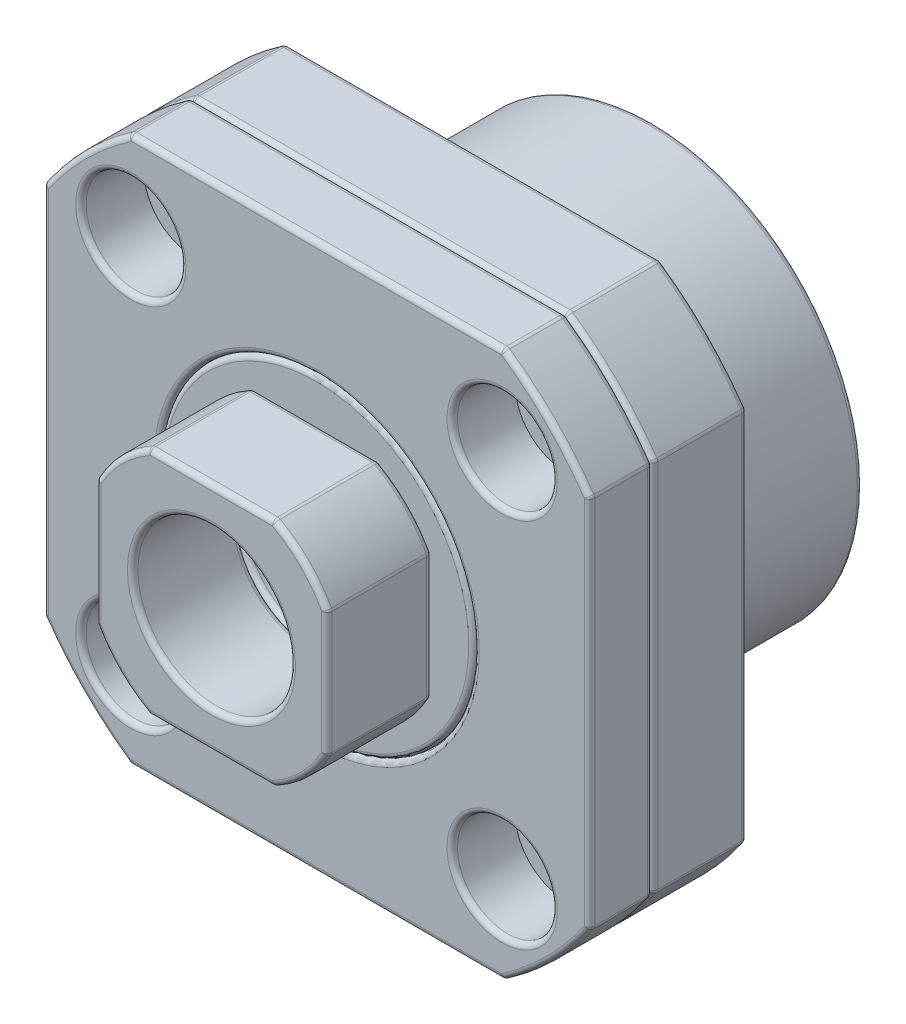
from build123d import *

# Parameters (mm, degrees)
SKETCH1_W            = 52
SKETCH1_H            = 52
SKETCH1_R            = 4.75
BOSS_EXTRUDE1_DEPTH  = 6
SKETCH2_OUTSIDE_W    = 68.756
SKETCH2_OUTSIDE_H    = 68.756
SKETCH2_OUTSIDE_R    = 31.5
CUT_EXTRUDE2_DEPTH   = 6
SKETCH3_R            = 16
BOSS_EXTRUDE2_DEPTH  = 1
SKETCH4_R            = 15
CUT_EXTRUDE3_DEPTH   = 7
SKETCH5_R            = 15
SKETCH5_R_2          = 7.5
BOSS_EXTRUDE4_DEPTH  = 7
FILLET1_R            = 0.5
SKETCH6_W            = 52
SKETCH6_H            = 52
SKETCH6_R            = 16
SKETCH6_R_2          = 2.75
BOSS_EXTRUDE5_DEPTH  = 9
SKETCH7_OUTSIDE_W    = 69.01
SKETCH7_OUTSIDE_H    = 69.01
SKETCH7_OUTSIDE_R    = 31.5
CUT_EXTRUDE5_DEPTH   = 9
SKETCH8_R            = 20
SKETCH8_R_2          = 16
BOSS_EXTRUDE6_DEPTH  = 17
SKETCH10_R           = 16
SKETCH10_R_2         = 15
BOSS_EXTRUDE7_DEPTH  = 6
SKETCH11_R           = 16
SKETCH11_R_2         = 7.5
BOSS_EXTRUDE8_DEPTH  = 17
FILLET2_R            = 0.5
SKETCH12_R           = 15
SKETCH12_R_2         = 7.5
BOSS_EXTRUDE9_DEPTH  = 7
FILLET3_R            = 0.5
FILLET4_R            = 0.5
SKETCH13_W           = 22
SKETCH13_H           = 22
BOSS_EXTRUDE10_DEPTH = 10
SKETCH14_OUTSIDE_W   = 70.938
SKETCH14_OUTSIDE_H   = 70.938
SKETCH14_OUTSIDE_R   = 12.5
CUT_EXTRUDE6_DEPTH   = 10
SKETCH15_R           = 7.5
CUT_EXTRUDE7_DEPTH   = 10
FILLET5_R            = 0.5
FILLET6_R            = 0.5


with BuildPart() as part:
    # Sketch1 → Boss-Extrude1 (new body)
    with BuildSketch(Plane.XY):
        Rectangle(SKETCH1_W, SKETCH1_H)
        with Locations((-17.67766953, -17.67766953)):
            Circle(SKETCH1_R, mode=Mode.SUBTRACT)
        with Locations((17.67766953, -17.67766953)):
            Circle(SKETCH1_R, mode=Mode.SUBTRACT)
        with Locations((17.67766953, 17.67766953)):
            Circle(SKETCH1_R, mode=Mode.SUBTRACT)
        with Locations((-17.67766953, 17.67766953)):
            Circle(SKETCH1_R, mode=Mode.SUBTRACT)
    extrude(amount=BOSS_EXTRUDE1_DEPTH)

    # Sketch2 outside → Cut-Extrude2 (cut)
    with BuildSketch(Plane.XY):
        Rectangle(SKETCH2_OUTSIDE_W, SKETCH2_OUTSIDE_H)
        Circle(SKETCH2_OUTSIDE_R, mode=Mode.SUBTRACT)
    extrude(amount=CUT_EXTRUDE2_DEPTH, mode=Mode.SUBTRACT)

    # Sketch3 → Boss-Extrude2 (add)
    with BuildSketch(Plane.XY):
        Circle(SKETCH3_R)
    extrude(amount=-BOSS_EXTRUDE2_DEPTH)

    # Sketch4 → Cut-Extrude3 (cut)
    with BuildSketch(Plane.XY.offset(6)):
        Circle(SKETCH4_R)
    extrude(amount=-CUT_EXTRUDE3_DEPTH, mode=Mode.SUBTRACT)

    # Fillet6
    fillet6_edges = [part.edges().sort_by_distance(p)[0] for p in [
        (-22.42766953, -17.67766953, 6),
        (12.92766953, -17.67766953, 6),
        (12.92766953, 17.67766953, 6),
        (-22.42766953, 17.67766953, 6),
        (0, 26, 0),
        (0, 26, 6),
        (17.783419244, 26, 3),
        (-17.783419244, 26, 3),
        (26, 0, 0),
        (26, 0, 6),
        (0, -26, 0),
        (0, -26, 6),
        (-26, 0, 0),
        (-26, 0, 6),
        (-22.273863607, -22.273863607, 0),
        (22.273863607, -22.273863607, 0),
        (22.273863607, 22.273863607, 0),
        (-22.273863607, 22.273863607, 0),
        (-26, -17.783419244, 3),
        (-22.273863607, -22.273863607, 6),
        (-17.783419244, -26, 3),
        (-22.273863607, 22.273863607, 6),
        (-26, 17.783419244, 3),
        (17.783419244, -26, 3),
        (22.273863607, -22.273863607, 6),
        (26, -17.783419244, 3),
        (26, 17.783419244, 3),
        (22.273863607, 22.273863607, 6),
        (-15, 0, 6),
    ]]
    fillet(fillet6_edges, radius=FILLET6_R)


with BuildPart() as body_2:
    # Sketch5 → Boss-Extrude4 (new body)
    with BuildSketch(Plane.XY.offset(6)):
        Circle(SKETCH5_R)
        Circle(SKETCH5_R_2, mode=Mode.SUBTRACT)
    extrude(amount=-BOSS_EXTRUDE4_DEPTH)

    # Fillet1
    fillet1_edges = [body_2.edges().sort_by_distance(p)[0] for p in [
        (-15, 0, 6),
        (-15, 0, -1),
        (-7.5, 0, -1),
        (-7.5, 0, 6),
    ]]
    fillet(fillet1_edges, radius=FILLET1_R)


with BuildPart() as body_3:
    # Sketch6 → Boss-Extrude5 (new body)
    with BuildSketch(Plane.XY):
        Rectangle(SKETCH6_W, SKETCH6_H)
        Circle(SKETCH6_R, mode=Mode.SUBTRACT)
        with Locations((-17.67766953, 17.67766953)):
            Circle(SKETCH6_R_2, mode=Mode.SUBTRACT)
        with Locations((17.67766953, 17.67766953)):
            Circle(SKETCH6_R_2, mode=Mode.SUBTRACT)
        with Locations((17.67766953, -17.67766953)):
            Circle(SKETCH6_R_2, mode=Mode.SUBTRACT)
        with Locations((-17.67766953, -17.67766953)):
            Circle(SKETCH6_R_2, mode=Mode.SUBTRACT)
    extrude(amount=-BOSS_EXTRUDE5_DEPTH)

    # Sketch7 outside → Cut-Extrude5 (cut)
    with BuildSketch(Plane.XY):
        Rectangle(SKETCH7_OUTSIDE_W, SKETCH7_OUTSIDE_H)
        Circle(SKETCH7_OUTSIDE_R, mode=Mode.SUBTRACT)
    extrude(amount=-CUT_EXTRUDE5_DEPTH, mode=Mode.SUBTRACT)

    # Sketch8 → Boss-Extrude6 (add)
    with BuildSketch(Plane.XY.offset(-9)):
        Circle(SKETCH8_R)
        Circle(SKETCH8_R_2, mode=Mode.SUBTRACT)
    extrude(amount=-BOSS_EXTRUDE6_DEPTH)

    # Sketch10 → Boss-Extrude7 (add)
    with BuildSketch(Plane.XY.offset(-26)):
        Circle(SKETCH10_R)
        Circle(SKETCH10_R_2, mode=Mode.SUBTRACT)
    extrude(amount=BOSS_EXTRUDE7_DEPTH)

    # Fillet4
    fillet4_edges = [body_3.edges().sort_by_distance(p)[0] for p in [
        (-15, 0, -26),
        (-26, 0, 0),
        (0, -26, 0),
        (26, 0, 0),
        (0, 26, 0),
        (-22.273863607, -22.273863607, 0),
        (22.273863607, -22.273863607, 0),
        (-22.273863607, 22.273863607, 0),
        (-26, 0, -9),
        (0, 26, -9),
        (26, 0, -9),
        (0, -26, -9),
        (-22.273863607, 22.273863607, -9),
        (22.273863607, 22.273863607, -9),
        (22.273863607, -22.273863607, -9),
        (-26, -17.783419244, -4.5),
        (-17.783419244, -26, -4.5),
        (-26, 17.783419244, -4.5),
        (-17.783419244, 26, -4.5),
        (22.273863607, 22.273863607, 0),
        (17.783419244, 26, -4.5),
        (26, 17.783419244, -4.5),
        (-22.273863607, -22.273863607, -9),
        (26, -17.783419244, -4.5),
        (17.783419244, -26, -4.5),
        (-20, 0, -9),
        (-20, 0, -26),
    ]]
    fillet(fillet4_edges, radius=FILLET4_R)


with BuildPart() as body_4:
    # Sketch11 → Boss-Extrude8 (new body)
    with BuildSketch(Plane.XY.offset(-1)):
        Circle(SKETCH11_R)
        Circle(SKETCH11_R_2, mode=Mode.SUBTRACT)
    extrude(amount=-BOSS_EXTRUDE8_DEPTH)

    # Fillet2
    fillet2_edges = [body_4.edges().sort_by_distance(p)[0] for p in [
        (-7.5, 0, -18),
        (-7.5, 0, -1),
    ]]
    fillet(fillet2_edges, radius=FILLET2_R)


with BuildPart() as body_5:
    # Sketch12 → Boss-Extrude9 (new body)
    with BuildSketch(Plane.XY.offset(-26)):
        Circle(SKETCH12_R)
        Circle(SKETCH12_R_2, mode=Mode.SUBTRACT)
    extrude(amount=BOSS_EXTRUDE9_DEPTH)

    # Fillet3
    fillet3_edges = [body_5.edges().sort_by_distance(p)[0] for p in [
        (-15, 0, -26),
        (-7.5, 0, -26),
        (-7.5, 0, -19),
    ]]
    fillet(fillet3_edges, radius=FILLET3_R)


with BuildPart() as body_6:
    # Sketch13 → Boss-Extrude10 (new body)
    with BuildSketch(Plane.XY.offset(6)):
        Rectangle(SKETCH13_W, SKETCH13_H)
    extrude(amount=BOSS_EXTRUDE10_DEPTH)

    # Sketch14 outside → Cut-Extrude6 (cut)
    with BuildSketch(Plane.XY.offset(16)):
        Rectangle(SKETCH14_OUTSIDE_W, SKETCH14_OUTSIDE_H)
        Circle(SKETCH14_OUTSIDE_R, mode=Mode.SUBTRACT)
    extrude(amount=-CUT_EXTRUDE6_DEPTH, mode=Mode.SUBTRACT)

    # Sketch15 → Cut-Extrude7 (cut)
    with BuildSketch(Plane.XY.offset(16)):
        Circle(SKETCH15_R)
    extrude(amount=-CUT_EXTRUDE7_DEPTH, mode=Mode.SUBTRACT)

    # Fillet5
    fillet5_edges = [body_6.edges().sort_by_distance(p)[0] for p in [
        (-11, 0, 6),
        (0, 11, 6),
        (11, 0, 6),
        (0, -11, 6),
        (-8.838834765, -8.838834765, 6),
        (8.838834765, -8.838834765, 6),
        (-8.838834765, 8.838834765, 6),
        (-11, 0, 16),
        (0, -11, 16),
        (11, 0, 16),
        (0, 11, 16),
        (8.838834765, 8.838834765, 6),
        (-8.838834765, 8.838834765, 16),
        (-8.838834765, -8.838834765, 16),
        (-11, 5.937171044, 11),
        (-11, -5.937171044, 11),
        (8.838834765, -8.838834765, 16),
        (-5.937171044, -11, 11),
        (5.937171044, -11, 11),
        (8.838834765, 8.838834765, 16),
        (11, -5.937171044, 11),
        (11, 5.937171044, 11),
        (5.937171044, 11, 11),
        (-5.937171044, 11, 11),
        (-7.5, 0, 6),
        (-7.5, 0, 16),
    ]]
    fillet(fillet5_edges, radius=FILLET5_R)


solid = Compound([part.part, body_2.part, body_3.part, body_4.part, body_5.part, body_6.part])
